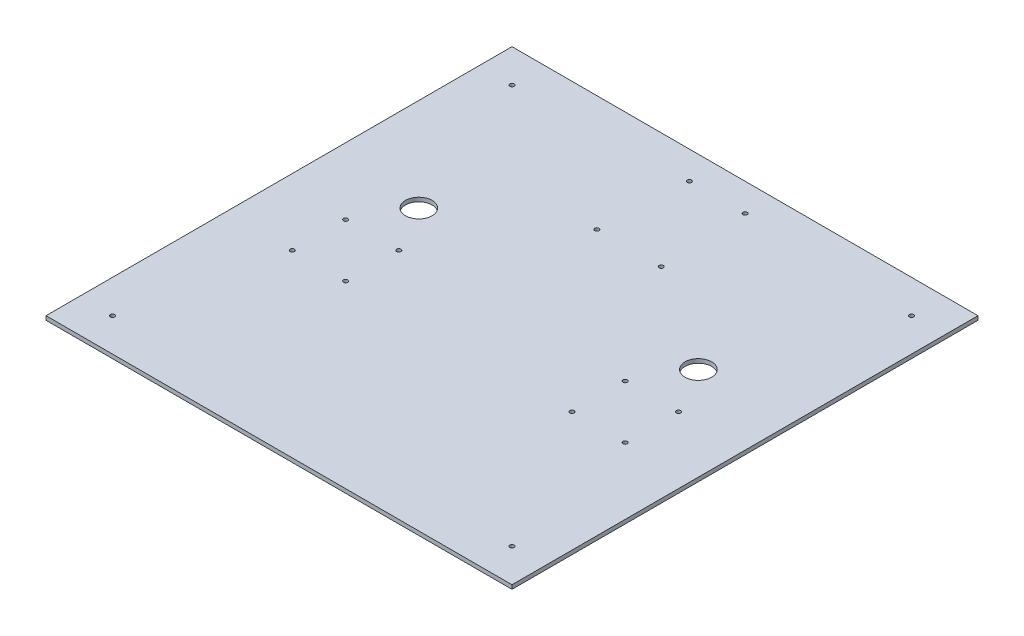
from build123d import *

# Parameters (mm, degrees)
SKETCH1_W           = 350.000000098
SKETCH1_H           = 350.000000098
SKETCH1_R           = 1.6
BOSS_EXTRUDE1_DEPTH = 3
SKETCH2_R           = 10
SKETCH2_R_2         = 1.6
CUT_EXTRUDE1_DEPTH  = 3


with BuildPart() as part:
    # Sketch1 → Boss-Extrude1 (new body)
    with BuildSketch(Plane(origin=(0, 0, 0), x_dir=(1, 0, 0), z_dir=(0, 1, 0))):
        Rectangle(SKETCH1_W, SKETCH1_H)
        with Locations((-150, 150)):
            Circle(SKETCH1_R, mode=Mode.SUBTRACT)
        with Locations((-150, -150)):
            Circle(SKETCH1_R, mode=Mode.SUBTRACT)
        with Locations((150, -150)):
            Circle(SKETCH1_R, mode=Mode.SUBTRACT)
        with Locations((150, 150)):
            Circle(SKETCH1_R, mode=Mode.SUBTRACT)
    extrude(amount=BOSS_EXTRUDE1_DEPTH)

    # Sketch2 → Cut-Extrude1 (cut)
    with BuildSketch(Plane(origin=(0, 3, 0), x_dir=(1, 0, 0), z_dir=(0, 1, 0))):
        with Locations((-105, 35)):
            Circle(SKETCH2_R)
        with Locations((105, 35)):
            Circle(SKETCH2_R)
        with Locations((-20.861599962, 154.028549732)):
            Circle(SKETCH2_R_2)
        with Locations((-24.234411868, 87.928549732)):
            Circle(SKETCH2_R_2)
        with Locations((21.048400038, 154.028549732)):
            Circle(SKETCH2_R_2)
        with Locations((24.155588132, 87.928549732)):
            Circle(SKETCH2_R_2)
        with Locations((-125, 0)):
            Circle(SKETCH2_R_2)
        with Locations((-85, 0)):
            Circle(SKETCH2_R_2)
        with Locations((-125, -40)):
            Circle(SKETCH2_R_2)
        with Locations((-85, -40)):
            Circle(SKETCH2_R_2)
        with Locations((85, 0)):
            Circle(SKETCH2_R_2)
        with Locations((125, 0)):
            Circle(SKETCH2_R_2)
        with Locations((85, -40)):
            Circle(SKETCH2_R_2)
        with Locations((125, -40)):
            Circle(SKETCH2_R_2)
    extrude(amount=-CUT_EXTRUDE1_DEPTH, mode=Mode.SUBTRACT)


solid = part.part
